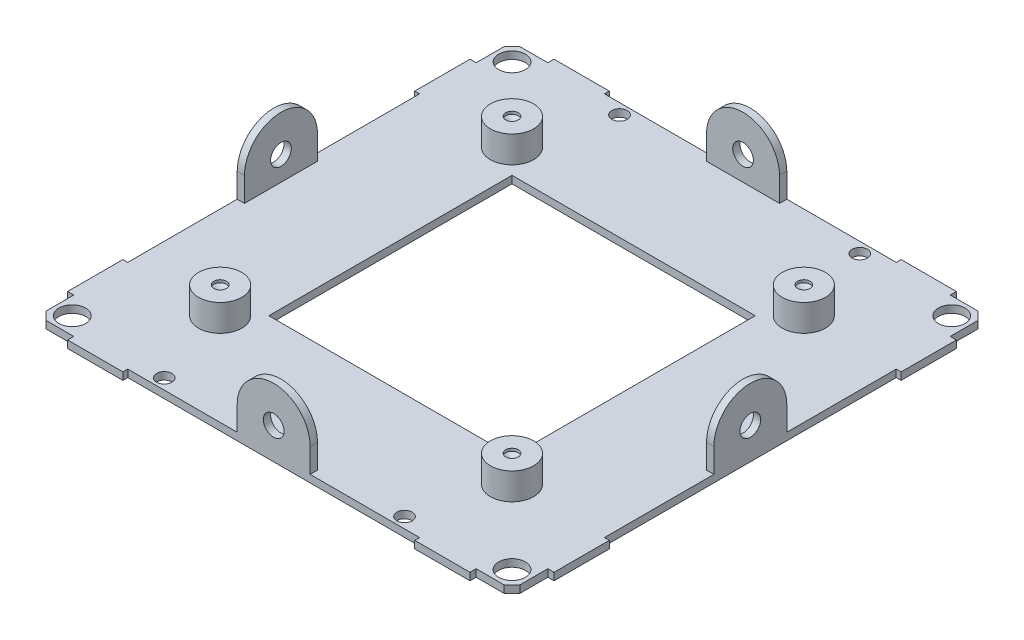
from build123d import *

# Parameters (mm, degrees)
SKETCH1_R                 = 2.7503
SKETCH1_R_2               = 1.575
SKETCH1_W                 = 50
SKETCH1_H                 = 50
BOSS_EXTRUDE1_DEPTH       = 1.524
SKETCH2_W                 = 15
SKETCH2_H                 = 2.5
SKETCH2_W_2               = 2.5
SKETCH2_H_2               = 15
BOSS_EXTRUDE2_DEPTH       = 12.476
SKETCH3_R                 = 2.125
CUT_EXTRUDE1_DEPTH        = 1
CUT_EXTRUDE1_DEPTH_BACK   = 101
SKETCH4_R                 = 2.125
CUT_EXTRUDE2_DEPTH        = 1
CUT_EXTRUDE2_DEPTH_BACK   = 101
SKETCH5_W                 = 60
SKETCH5_H                 = 1
SKETCH5_W_2               = 1
SKETCH5_H_2               = 60
CUT_EXTRUDE3_DEPTH        = 1
CUT_EXTRUDE3_DEPTH_BACK   = 15
SKETCH6_R                 = 4.445
BOSS_EXTRUDE3_DEPTH       = 5.5
F_5_40_TAPPED_HOLE1_D     = 2.5781
F_5_40_TAPPED_HOLE1_DEPTH = 0.55
F_5_40_TAPPED_HOLE1_TIP   = 0.774539381


with BuildPart() as part:
    # Sketch1 → Boss-Extrude1 (new body)
    with BuildSketch(Plane(origin=(0, 0, 0), x_dir=(1, 0, 0), z_dir=(0, 1, 0))):
        Polygon((41.364, 50), (-41.364, 50), (-41.364, 48.73), (-47.079, 48.73), (-48.73, 47.079), (-48.73, 41.364), (-50, 41.364), (-50, -41.364), (-48.73, -41.364), (-48.73, -47.079), (-47.079, -48.73), (-41.364, -48.73), (-41.364, -50), (41.364, -50), (41.364, -48.73), (47.079, -48.73), (48.73, -47.079), (48.73, -41.364), (50, -41.364), (50, 41.364), (48.73, 41.364), (48.73, 47.079), (47.079, 48.73), (41.364, 48.73), align=None)
        with Locations((-45.2, -45.2)):
            Circle(SKETCH1_R, mode=Mode.SUBTRACT)
        with Locations((-24.7, -46.8)):
            Circle(SKETCH1_R_2, mode=Mode.SUBTRACT)
        with Locations((24.7, -46.8)):
            Circle(SKETCH1_R_2, mode=Mode.SUBTRACT)
        with Locations((45.2, -45.2)):
            Circle(SKETCH1_R, mode=Mode.SUBTRACT)
        Rectangle(SKETCH1_W, SKETCH1_H, mode=Mode.SUBTRACT)
        with Locations((-45.2, 45.2)):
            Circle(SKETCH1_R, mode=Mode.SUBTRACT)
        with Locations((-24.7, 46.8)):
            Circle(SKETCH1_R_2, mode=Mode.SUBTRACT)
        with BuildLine():
            ThreePointArc((26.275, 46.8), (24.7, 45.225), (23.125, 46.8))
            ThreePointArc((23.125, 46.8), (24.7, 48.375), (26.275, 46.8))
        make_face(mode=Mode.SUBTRACT)
        with Locations((45.2, 45.2)):
            Circle(SKETCH1_R, mode=Mode.SUBTRACT)
    extrude(amount=BOSS_EXTRUDE1_DEPTH)

    # Sketch2 → Boss-Extrude2 (add)
    with BuildSketch(Plane(origin=(0, 1.524, 0), x_dir=(1, 0, 0), z_dir=(0, 1, 0))):
        with Locations((0, 48.75)):
            Rectangle(SKETCH2_W, SKETCH2_H)
        with Locations((48.75, 0)):
            Rectangle(SKETCH2_W_2, SKETCH2_H_2)
        with Locations((0, -48.75)):
            Rectangle(SKETCH2_W, SKETCH2_H)
        with Locations((-48.75, 0)):
            Rectangle(SKETCH2_W_2, SKETCH2_H_2)
    extrude(amount=BOSS_EXTRUDE2_DEPTH)

    # Sketch3 → Cut-Extrude1 (cut, two sides)
    with BuildSketch(Plane.XY.offset(50)) as cut_extrude1_sk:
        with BuildLine():
            ThreePointArc((0, 14), (5.303300859, 11.803300859), (7.5, 6.5))
            Line((7.5, 6.5), (7.5, 14))
            Line((7.5, 14), (0, 14))
        make_face()
        with BuildLine():
            ThreePointArc((-7.5, 6.5), (-5.303300859, 11.803300859), (0, 14))
            Line((0, 14), (-7.5, 14))
            Line((-7.5, 14), (-7.5, 6.5))
        make_face()
        with Locations((0, 6.5)):
            Circle(SKETCH3_R)
    extrude(amount=CUT_EXTRUDE1_DEPTH, mode=Mode.SUBTRACT)
    extrude(cut_extrude1_sk.sketch, amount=-CUT_EXTRUDE1_DEPTH_BACK, mode=Mode.SUBTRACT)

    # Sketch4 → Cut-Extrude2 (cut, two sides)
    with BuildSketch(Plane.ZY.offset(50)) as cut_extrude2_sk:
        with Locations((0, 6.5)):
            Circle(SKETCH4_R)
        with BuildLine():
            ThreePointArc((0, 14), (5.303300859, 11.803300859), (7.5, 6.5))
            Line((7.5, 6.5), (7.5, 14))
            Line((7.5, 14), (0, 14))
        make_face()
        with BuildLine():
            ThreePointArc((-7.5, 6.5), (-5.303300859, 11.803300859), (0, 14))
            Line((0, 14), (-7.5, 14))
            Line((-7.5, 14), (-7.5, 6.5))
        make_face()
    extrude(amount=CUT_EXTRUDE2_DEPTH, mode=Mode.SUBTRACT)
    extrude(cut_extrude2_sk.sketch, amount=-CUT_EXTRUDE2_DEPTH_BACK, mode=Mode.SUBTRACT)

    # Sketch5 → Cut-Extrude3 (cut, two sides)
    with BuildSketch(Plane.XZ) as cut_extrude3_sk:
        with Locations((0, -49.5)):
            Rectangle(SKETCH5_W, SKETCH5_H)
        with Locations((-49.5, 0)):
            Rectangle(SKETCH5_W_2, SKETCH5_H_2)
        with Locations((0, 49.5)):
            Rectangle(SKETCH5_W, SKETCH5_H)
        with Locations((49.5, 0)):
            Rectangle(SKETCH5_W_2, SKETCH5_H_2)
    extrude(amount=CUT_EXTRUDE3_DEPTH, mode=Mode.SUBTRACT)
    extrude(cut_extrude3_sk.sketch, amount=-CUT_EXTRUDE3_DEPTH_BACK, mode=Mode.SUBTRACT)

    # Sketch6 → Boss-Extrude3 (add)
    with BuildSketch(Plane(origin=(0, 1.524, 0), x_dir=(1, 0, 0), z_dir=(0, 1, 0))):
        with Locations((30, 30)):
            Circle(SKETCH6_R)
        with Locations((30, -30)):
            Circle(SKETCH6_R)
        with Locations((-30, -30)):
            Circle(SKETCH6_R)
        with Locations((-30, 30)):
            Circle(SKETCH6_R)
    extrude(amount=BOSS_EXTRUDE3_DEPTH)

    # #5-40 Tapped Hole1
    with Locations(Plane(origin=(0, 7.024, 0), x_dir=(1, 0, 0), z_dir=(0, 1, 0))):
        with Locations((-17.222965343, 16.834933913), (-30, 30), (-30, -30), (30, -30), (30, 30)):
            Hole(F_5_40_TAPPED_HOLE1_D / 2, depth=F_5_40_TAPPED_HOLE1_DEPTH)
            with Locations((0, 0, -(F_5_40_TAPPED_HOLE1_DEPTH + F_5_40_TAPPED_HOLE1_TIP / 2))):  # 118° drill point
                Cone(0, F_5_40_TAPPED_HOLE1_D / 2, F_5_40_TAPPED_HOLE1_TIP, mode=Mode.SUBTRACT)


solid = part.part
